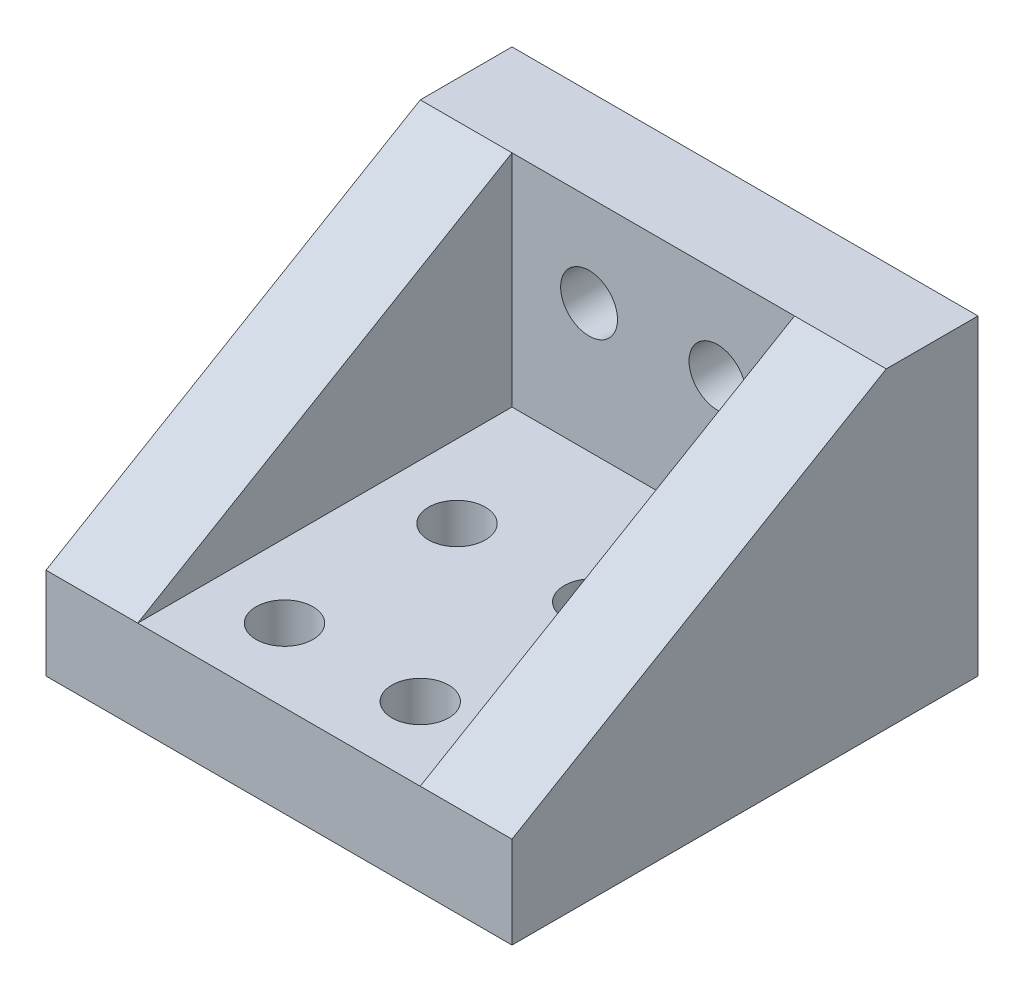
from build123d import *

# Parameters (mm, degrees)
BOSS_EXTRUDE2_DEPTH = 25.4
CUT_EXTRUDE1_REACH  = 41.741
SKETCH4_R           = 1.55
RIB12_REACH         = 41.741
SKETCH8_WALL_W      = 105.149018068
SKETCH8_WALL_H      = 5
CUT_EXTRUDE2_REACH  = 39.872
SKETCH5_R           = 1.55


with BuildPart() as part:
    # Sketch3 → Boss-Extrude2 (new body)
    with BuildSketch(Plane(origin=(0, 0, 0), x_dir=(0, 0, -1), z_dir=(1, 0, 0))):
        Polygon((0, 0), (0, 5), (20.4, 5), (20.4, 17), (25.4, 17), (25.4, 0), align=None)
    extrude(amount=BOSS_EXTRUDE2_DEPTH)

    # Sketch4 → Cut-Extrude1 (cut, up to next)
    with BuildSketch(Plane(origin=(0, 0, -25.4), x_dir=(-1, 0, 0), z_dir=(0, 0, -1)), mode=Mode.PRIVATE) as cut_extrude1_sk1:
        with Locations(Location((-16.2, 12, 0), (0, 0, 90))):
            Circle(SKETCH4_R)
    cut_extrude1_tool1 = extrude(cut_extrude1_sk1.sketch, amount=-CUT_EXTRUDE1_REACH, mode=Mode.PRIVATE) & part.part
    # Sketch4 → Cut-Extrude1 (cut, up to next)
    with BuildSketch(Plane(origin=(0, 0, -25.4), x_dir=(-1, 0, 0), z_dir=(0, 0, -1)), mode=Mode.PRIVATE) as cut_extrude1_sk2:
        with Locations(Location((-9.2, 12, 0), (0, 0, 90))):
            Circle(SKETCH4_R)
    cut_extrude1_tool2 = extrude(cut_extrude1_sk2.sketch, amount=-CUT_EXTRUDE1_REACH, mode=Mode.PRIVATE) & part.part
    add(cut_extrude1_tool1.solids().sort_by_distance((16.2, 12, -25.4))[0], mode=Mode.SUBTRACT)
    add(cut_extrude1_tool2.solids().sort_by_distance((9.2, 12, -25.4))[0], mode=Mode.SUBTRACT)

    # Sketch8 wall → Rib12 (add, up to next)
    with BuildSketch(Plane(origin=(0, 11, -10.2), x_dir=(0, -0.507020126563, 0.861934215158), z_dir=(0, 0.861934215158, 0.507020126563)), mode=Mode.PRIVATE) as rib12_sk1:
        with Locations((0, 2.5)):
            Rectangle(SKETCH8_WALL_W, SKETCH8_WALL_H)
    rib12_tool1 = extrude(rib12_sk1.sketch, amount=-RIB12_REACH, mode=Mode.PRIVATE) - part.part
    rib12 = rib12_tool1.solids().sort_by_distance((0, 11, -10.2))[0]
    add(rib12)

    # Mirror1: Rib12 across plane
    add(rib12.mirror(Plane(origin=(12.7, 0, 0), x_dir=(0, 0, 1), z_dir=(1, 0, 0))))

    # Sketch5 → Cut-Extrude2 (cut, up to next)
    with BuildSketch(Plane(origin=(0, 5, 0), x_dir=(1, 0, 0), z_dir=(0, 1, 0)), mode=Mode.PRIVATE) as cut_extrude2_sk1:
        with Locations(Location((9, 4, 0), (0, 0, 270))):
            Circle(SKETCH5_R)
    cut_extrude2_tool1 = extrude(cut_extrude2_sk1.sketch, amount=-CUT_EXTRUDE2_REACH, mode=Mode.PRIVATE) & part.part
    # Sketch5 → Cut-Extrude2 (cut, up to next)
    with BuildSketch(Plane(origin=(0, 5, 0), x_dir=(1, 0, 0), z_dir=(0, 1, 0)), mode=Mode.PRIVATE) as cut_extrude2_sk2:
        with Locations(Location((9, 13.4, 0), (0, 0, 270))):
            Circle(SKETCH5_R)
    cut_extrude2_tool2 = extrude(cut_extrude2_sk2.sketch, amount=-CUT_EXTRUDE2_REACH, mode=Mode.PRIVATE) & part.part
    # Sketch5 → Cut-Extrude2 (cut, up to next)
    with BuildSketch(Plane(origin=(0, 5, 0), x_dir=(1, 0, 0), z_dir=(0, 1, 0)), mode=Mode.PRIVATE) as cut_extrude2_sk3:
        with Locations(Location((16.4, 13.4, 0), (0, 0, 270))):
            Circle(SKETCH5_R)
    cut_extrude2_tool3 = extrude(cut_extrude2_sk3.sketch, amount=-CUT_EXTRUDE2_REACH, mode=Mode.PRIVATE) & part.part
    # Sketch5 → Cut-Extrude2 (cut, up to next)
    with BuildSketch(Plane(origin=(0, 5, 0), x_dir=(1, 0, 0), z_dir=(0, 1, 0)), mode=Mode.PRIVATE) as cut_extrude2_sk4:
        with Locations(Location((16.4, 4, 0), (0, 0, 270))):
            Circle(SKETCH5_R)
    cut_extrude2_tool4 = extrude(cut_extrude2_sk4.sketch, amount=-CUT_EXTRUDE2_REACH, mode=Mode.PRIVATE) & part.part
    add(cut_extrude2_tool1.solids().sort_by_distance((9, 5, -4))[0], mode=Mode.SUBTRACT)
    add(cut_extrude2_tool2.solids().sort_by_distance((9, 5, -13.4))[0], mode=Mode.SUBTRACT)
    add(cut_extrude2_tool3.solids().sort_by_distance((16.4, 5, -13.4))[0], mode=Mode.SUBTRACT)
    add(cut_extrude2_tool4.solids().sort_by_distance((16.4, 5, -4))[0], mode=Mode.SUBTRACT)


solid = part.part
